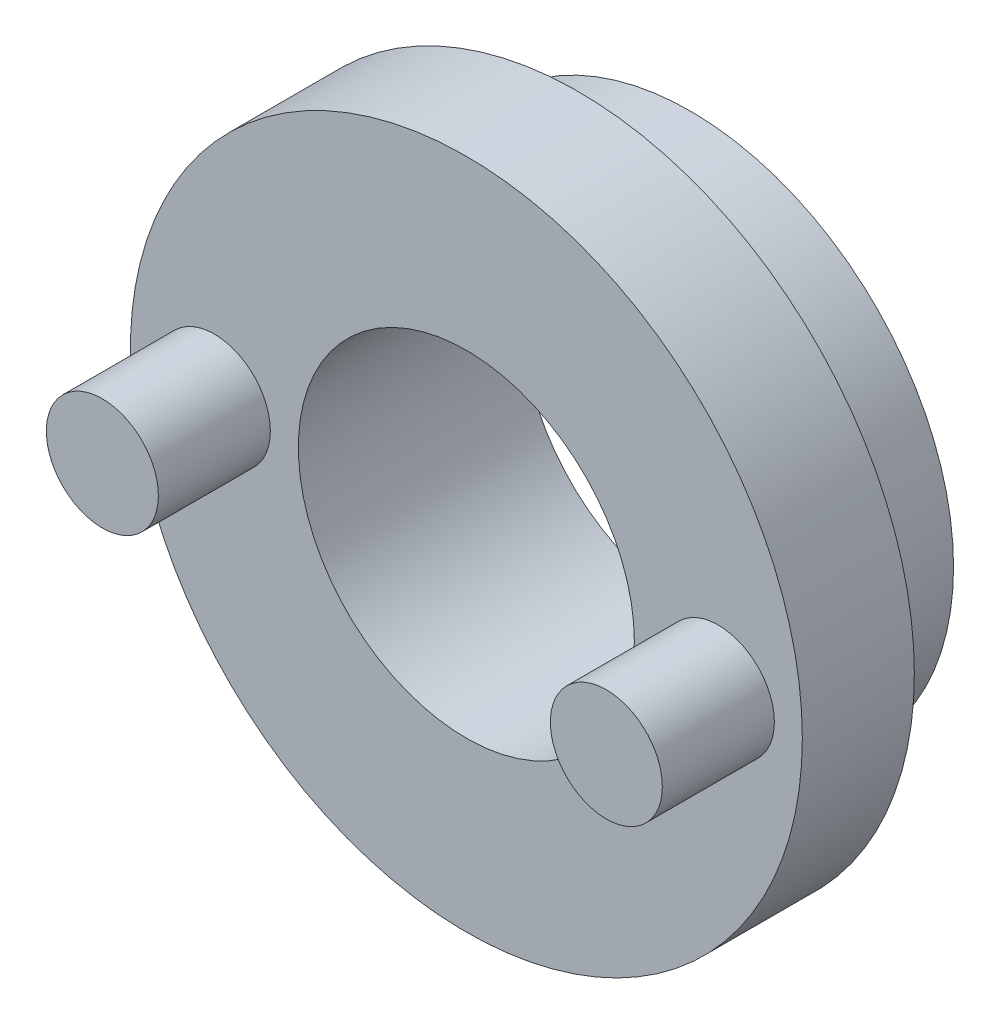
from build123d import *

# Parameters (mm, degrees)
SKETCH1_R           = 23.5
SKETCH1_R_2         = 15
BOSS_EXTRUDE1_DEPTH = 10
SKETCH2_R           = 30
SKETCH2_R_2         = 15
BOSS_EXTRUDE2_DEPTH = 10
CHAMFER1_SIZE       = 3
SKETCH3_R           = 5
BOSS_EXTRUDE3_DEPTH = 10


with BuildPart() as part:
    # Sketch1 → Boss-Extrude1 (new body)
    with BuildSketch(Plane.XY):
        Circle(SKETCH1_R)
        Circle(SKETCH1_R_2, mode=Mode.SUBTRACT)
    extrude(amount=-BOSS_EXTRUDE1_DEPTH)

    # Sketch2 → Boss-Extrude2 (add)
    with BuildSketch(Plane.XY):
        Circle(SKETCH2_R)
        Circle(SKETCH2_R_2, mode=Mode.SUBTRACT)
    extrude(amount=BOSS_EXTRUDE2_DEPTH)

    # Chamfer1
    chamfer1_edges = [part.edges().sort_by_distance(p)[0] for p in [
        (-23.5, 0, 0),
    ]]
    chamfer(chamfer1_edges, length=CHAMFER1_SIZE)

    # Sketch3 → Boss-Extrude3 (add)
    with BuildSketch(Plane.XY.offset(10)):
        with Locations((-22.5, 0)):
            Circle(SKETCH3_R)
        with Locations((22.5, 0)):
            Circle(SKETCH3_R)
    extrude(amount=BOSS_EXTRUDE3_DEPTH)


solid = part.part
